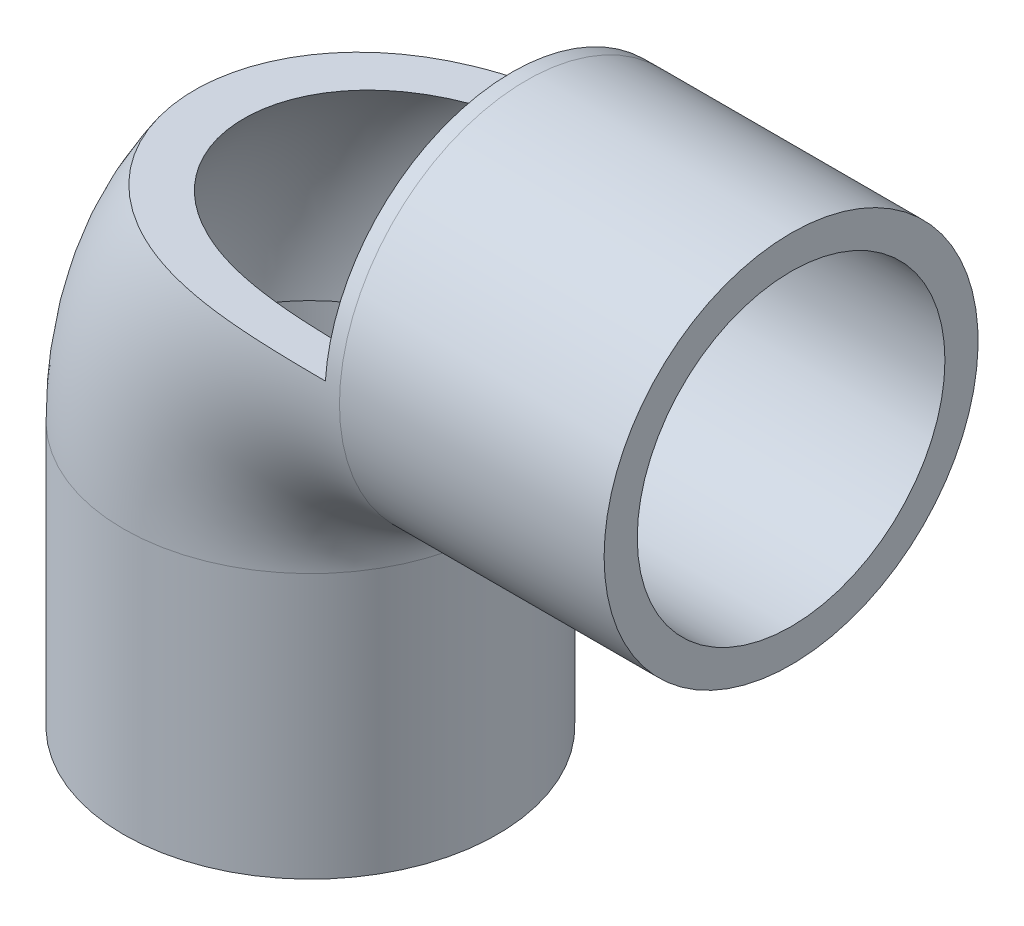
from build123d import *

# Parameters (mm, degrees)
SKETCH1_R           = 20.41525
SKETCH1_R_2         = 16.79575
BOSS_EXTRUDE1_DEPTH = 28.8925
SKETCH2_R           = 20.41525
SKETCH2_R_2         = 16.09725
REVOLVE1_ANGLE      = 90
SKETCH3_R           = 20.41525
SKETCH3_R_2         = 16.79575
BOSS_EXTRUDE2_DEPTH = 28.8925
SKETCH5_W           = 42.418
SKETCH5_H           = 19.05
CUT_EXTRUDE2_DEPTH  = 66.9925


with BuildPart() as part:
    # Sketch1 → Boss-Extrude1 (new body)
    with BuildSketch(Plane(origin=(0, 0, 0), x_dir=(1, 0, 0), z_dir=(0, 1, 0))):
        Circle(SKETCH1_R)
        Circle(SKETCH1_R_2, mode=Mode.SUBTRACT)
    extrude(amount=BOSS_EXTRUDE1_DEPTH)

    # Sketch2 → Revolve1 (revolve)
    with BuildSketch(Plane(origin=(0, 28.8925, 0), x_dir=(1, 0, 0), z_dir=(0, 1, 0))):
        Circle(SKETCH2_R)
        Circle(SKETCH2_R_2, mode=Mode.SUBTRACT)
    revolve(axis=Axis((23.59025, 28.8925, 20.41525), (0, 0, -1)), revolution_arc=REVOLVE1_ANGLE)

    # Sketch3 → Boss-Extrude2 (add)
    with BuildSketch(Plane(origin=(23.59025, 0, 0), x_dir=(0, 0, -1), z_dir=(1, 0, 0))):
        with Locations((0, 52.48275)):
            Circle(SKETCH3_R)
        with Locations((0, 52.48275)):
            Circle(SKETCH3_R_2, mode=Mode.SUBTRACT)
    extrude(amount=BOSS_EXTRUDE2_DEPTH)

    # Sketch5 → Cut-Extrude2 (cut)
    with BuildSketch(Plane(origin=(0, 28.8925, -20.41525), x_dir=(-1, 0, 0), z_dir=(0, 0, -1))):
        with Locations((-0.79375, 34.4805)):
            Rectangle(SKETCH5_W, SKETCH5_H)
    extrude(amount=-CUT_EXTRUDE2_DEPTH, mode=Mode.SUBTRACT)


solid = part.part
